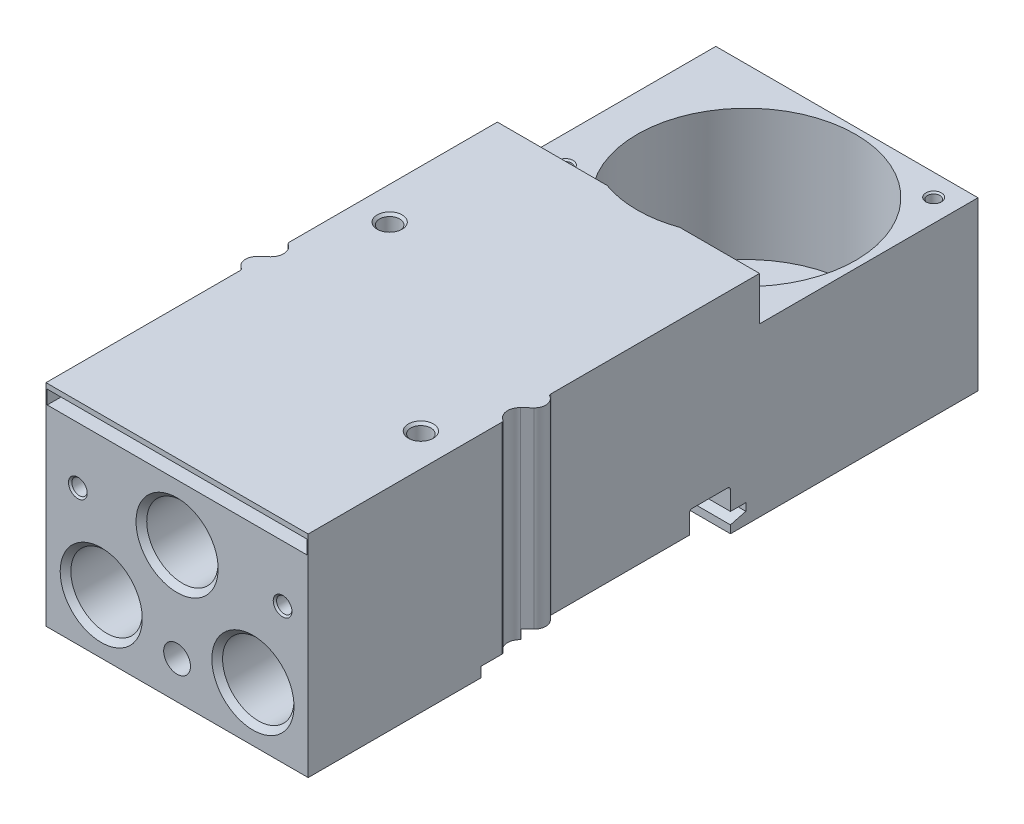
from build123d import *

# Parameters (mm, degrees)
BOSS_EXTRUDE1_DEPTH     = 33.8
CUT_EXTRUDE1_DEPTH      = 25
CUT_EXTRUDE1_DEPTH_BACK = 25
SKETCH3_W               = 42
SKETCH3_H               = 35
CUT_EXTRUDE2_DEPTH      = 7
SKETCH9_R               = 17.5
CUT_EXTRUDE3_DEPTH      = 28
SKETCH12_W              = 41.6
SKETCH12_H              = 2.2
CUT_EXTRUDE4_DEPTH      = 10
SKETCH13_W              = 10
SKETCH13_H              = 2.15


with BuildPart() as part:
    # Sketch1 → Boss-Extrude1 (new body)
    with BuildSketch(Plane(origin=(0, 1.3, 0), x_dir=(1, 0, 0), z_dir=(0, 1, 0))):
        with BuildLine():
            Line((-21, -22.541858429), (-21, -53.65))
            Line((-21, -53.65), (21, -53.65))
            Line((21, -53.65), (21, -22.654162541))
            ThreePointArc((21, -22.654162541), (20.938748215, -22.414370958), (20.769999986, -22.233330024))
            ThreePointArc((20.769999986, -22.233330024), (19.858228534, -20.731235829), (20.483912522, -19.089245057))
            Line((20.483912522, -19.089245057), (21.57947873, -18.064679449))
            ThreePointArc((21.57947873, -18.064679449), (22.138283161, -16.544955286), (21.250000071, -15.191154314))
            ThreePointArc((21.250000071, -15.191154314), (21.066987319, -15.008141607), (21, -14.758141571))
            Line((21, -14.758141571), (21, 53.65))
            Line((21, 53.65), (-21, 53.65))
            Line((-21, 53.65), (-21, -14.645837459))
            ThreePointArc((-21, -14.645837459), (-20.938748219, -14.885629035), (-20.77, -15.066669967))
            ThreePointArc((-20.77, -15.066669967), (-19.858228534, -16.568764162), (-20.483912522, -18.210754943))
            Line((-20.483912522, -18.210754943), (-21.57947873, -19.235320551))
            ThreePointArc((-21.57947873, -19.235320551), (-22.138283154, -20.755044775), (-21.249999964, -22.108845748))
            ThreePointArc((-21.249999964, -22.108845748), (-21.066987288, -22.291858447), (-21, -22.541858429))
        make_face()
    extrude(amount=BOSS_EXTRUDE1_DEPTH)

    # Sketch2 → Cut-Extrude1 (cut, two sides)
    with BuildSketch(Plane(origin=(0, 0, 0), x_dir=(0, 0, -1), z_dir=(1, 0, 0))) as cut_extrude1_sk:
        with BuildLine():
            Line((-26, 2.9), (-26, -8.174443219))
            Line((-26, -8.174443219), (14, -7.963716906))
            Line((14, -7.963716906), (14, 2.543524479))
            Line((14, 2.543524479), (16.45, 3.2))
            Line((16.45, 3.2), (16.45, 4.4))
            Line((16.45, 4.4), (14, 4.4))
            Line((14, 4.4), (14, 7.4))
            ThreePointArc((14, 7.4), (13.853553391, 7.753553391), (13.5, 7.9))
            Line((13.5, 7.9), (7.9, 7.9))
            ThreePointArc((7.9, 7.9), (7.546446609, 7.753553391), (7.4, 7.4))
            Line((7.4, 7.4), (7.4, 4.4))
            Line((7.4, 4.4), (-19.05, 4.4))
            Line((-19.05, 4.4), (-19.05, 2.9))
            Line((-19.05, 2.9), (-26, 2.9))
        make_face()
    extrude(amount=CUT_EXTRUDE1_DEPTH, mode=Mode.SUBTRACT)
    extrude(cut_extrude1_sk.sketch, amount=-CUT_EXTRUDE1_DEPTH_BACK, mode=Mode.SUBTRACT)

    # Sketch3 → Cut-Extrude2 (cut)
    with BuildSketch(Plane(origin=(0, 35.1, 0), x_dir=(1, 0, 0), z_dir=(0, 1, 0))):
        with Locations((0, 36.15)):
            Rectangle(SKETCH3_W, SKETCH3_H)
    extrude(amount=-CUT_EXTRUDE2_DEPTH, mode=Mode.SUBTRACT)

    # Sketch4 → Cut-Revolve1 (revolve, cut)
    with BuildSketch(Plane(origin=(0, 10.05, 0), x_dir=(1, 0, 0), z_dir=(0, 1, 0))):
        Polygon((-12.15, -43.922), (-6.4275, -43.922), (-6.4275, -52.794), (-5.5715, -53.65), (-12.15, -53.65), align=None)
    revolve(axis=Axis((-12.15, 10.05, 53.65), (0, 0, -1)), mode=Mode.SUBTRACT)

    # Sketch5 → Cut-Revolve2 (revolve, cut)
    with BuildSketch(Plane(origin=(0, 10.05, 0), x_dir=(1, 0, 0), z_dir=(0, 1, 0))):
        Polygon((12.15, -43.922), (17.8725, -43.922), (17.8725, -52.794), (18.7285, -53.65), (12.15, -53.65), align=None)
    revolve(axis=Axis((12.15, 10.05, 53.65), (0, 0, -1)), mode=Mode.SUBTRACT)

    # Sketch6 → Cut-Revolve3 (revolve, cut)
    with BuildSketch(Plane(origin=(0, 23.05, 0), x_dir=(1, 0, 0), z_dir=(0, 1, 0))):
        Polygon((0, -43.922), (5.7225, -43.922), (5.7225, -52.794), (6.5785, -53.65), (0, -53.65), align=None)
    revolve(axis=Axis((0, 23.05, 53.65), (0, 0, -1)), mode=Mode.SUBTRACT)

    # Sketch7 → Cut-Revolve4 (revolve, cut)
    with BuildSketch(Plane(origin=(-15.75, 0, 0), x_dir=(0, 0, -1), z_dir=(1, 0, 0))):
        Polygon((-3.85, 27.1), (-5.471, 27.1), (-5.471, 34.721), (-5.85, 35.1), (-3.85, 35.1), align=None)
    revolve(axis=Axis((-15.75, 35.1, 3.85), (0, -1, 0)), mode=Mode.SUBTRACT)

    # Sketch8 → Cut-Revolve5 (revolve, cut)
    with BuildSketch(Plane(origin=(15.75, 0, 0), x_dir=(0, 0, -1), z_dir=(1, 0, 0))):
        Polygon((-30.35, 27.1), (-31.971, 27.1), (-31.971, 34.721), (-32.35, 35.1), (-30.35, 35.1), align=None)
    revolve(axis=Axis((15.75, 35.1, 30.35), (0, -1, 0)), mode=Mode.SUBTRACT)

    # Sketch9 → Cut-Extrude3 (cut)
    with BuildSketch(Plane(origin=(0, 35.1, 0), x_dir=(1, 0, 0), z_dir=(0, 1, 0))):
        with Locations((2.4, 35.15)):
            Circle(SKETCH9_R)
    extrude(amount=-CUT_EXTRUDE3_DEPTH, mode=Mode.SUBTRACT)

    # Sketch10 → Cut-Revolve6 (revolve, cut)
    with BuildSketch(Plane(origin=(0, 23.05, 0), x_dir=(1, 0, 0), z_dir=(0, 1, 0))):
        Polygon((-15.9, -42.65), (-14.6705, -43.359852156), (-14.6705, -53.3795), (-14.4, -53.65), (-15.9, -53.65), align=None)
    revolve(axis=Axis((-15.9, 23.05, 53.65), (0, 0, -1)), mode=Mode.SUBTRACT)

    # Sketch11 → Cut-Revolve7 (revolve, cut)
    with BuildSketch(Plane(origin=(0, 23.05, 0), x_dir=(1, 0, 0), z_dir=(0, 1, 0))):
        Polygon((16.9, -42.65), (18.1295, -43.359852156), (18.1295, -53.3795), (18.4, -53.65), (16.9, -53.65), align=None)
    revolve(axis=Axis((16.9, 23.05, 53.65), (0, 0, -1)), mode=Mode.SUBTRACT)

    # Sketch12 → Cut-Extrude4 (cut)
    with BuildSketch(Plane.XY.offset(53.65)):
        with Locations((0, 33.2)):
            Rectangle(SKETCH12_W, SKETCH12_H)
    extrude(amount=-CUT_EXTRUDE4_DEPTH, mode=Mode.SUBTRACT)

    # Sketch13 → Cut-Revolve8 (revolve, cut)
    with BuildSketch(Plane(origin=(0, 0, 0), x_dir=(0, 0, -1), z_dir=(1, 0, 0))):
        with Locations((-48.65, 8.375)):
            Rectangle(SKETCH13_W, SKETCH13_H)
    revolve(axis=Axis((0, 7.3, 43.65), (0, 0, 1)), mode=Mode.SUBTRACT)

    # Sketch14 → Cut-Revolve9 (revolve, cut)
    with BuildSketch(Plane(origin=(17.4, 0, 0), x_dir=(0, 0, -1), z_dir=(1, 0, 0))):
        Polygon((50.15, 22.1), (49.1435, 22.1), (49.1435, 27.8565), (48.9, 28.1), (50.15, 28.1), align=None)
    revolve(axis=Axis((17.4, 28.1, -50.15), (0, -1, 0)), mode=Mode.SUBTRACT)

    # Sketch15 → Cut-Revolve10 (revolve, cut)
    with BuildSketch(Plane(origin=(-16.6, 0, 0), x_dir=(0, 0, -1), z_dir=(1, 0, 0))):
        Polygon((25.15, 22.1), (24.1435, 22.1), (24.1435, 27.8565), (23.9, 28.1), (25.15, 28.1), align=None)
    revolve(axis=Axis((-16.6, 28.1, -25.15), (0, -1, 0)), mode=Mode.SUBTRACT)

    # Sketch16 → Cut-Revolve11 (revolve, cut)
    with BuildSketch(Plane(origin=(0, 13, 0), x_dir=(1, 0, 0), z_dir=(0, 1, 0))):
        Polygon((-16.4, 53.65), (-14.525, 53.65), (-15.025, 53.15), (-15.025, 44.65), (-16.4, 44.65), align=None)
    revolve(axis=Axis((-16.4, 13, -44.65), (0, 0, -1)), mode=Mode.SUBTRACT)

    # Sketch17 → Cut-Revolve12 (revolve, cut)
    with BuildSketch(Plane(origin=(0, 13, 0), x_dir=(1, 0, 0), z_dir=(0, 1, 0))):
        Polygon((16.4, 53.65), (18.275, 53.65), (17.775, 53.15), (17.775, 44.65), (16.4, 44.65), align=None)
    revolve(axis=Axis((16.4, 13, -44.65), (0, 0, -1)), mode=Mode.SUBTRACT)


solid = part.part
